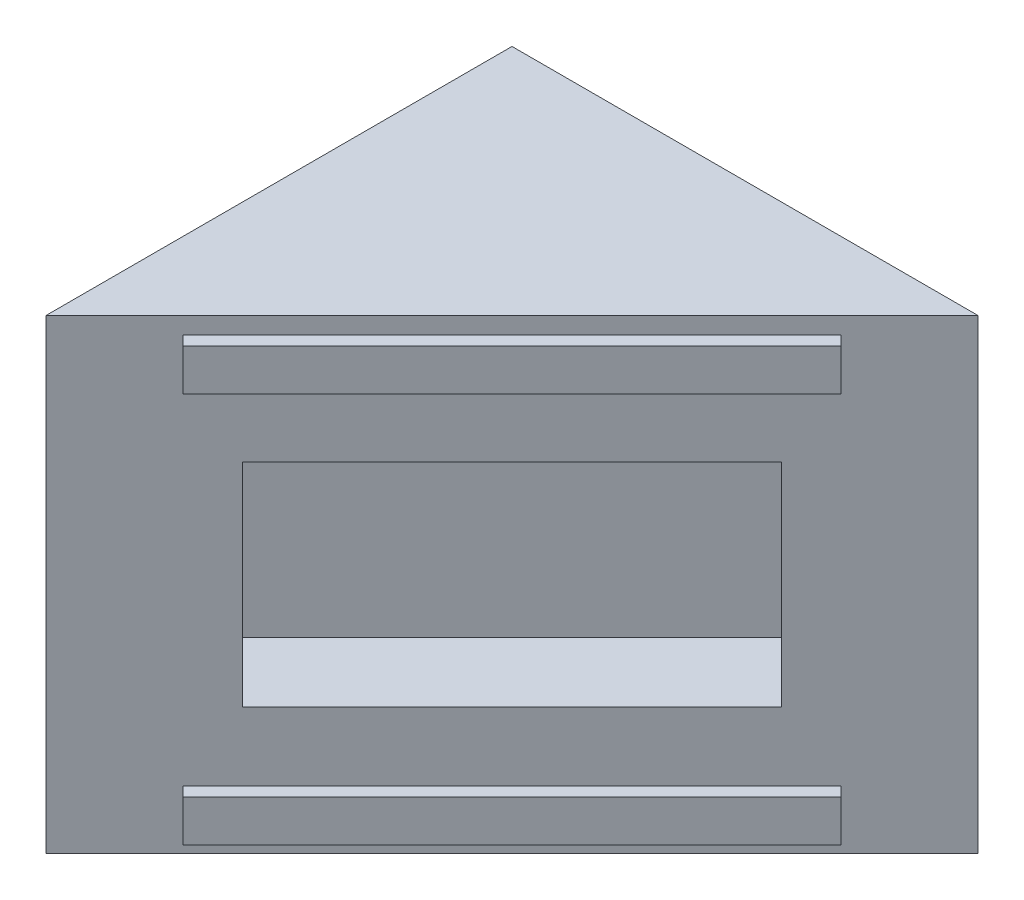
from build123d import *

# Parameters (mm, degrees)
SKETCH1_W           = 69.85
SKETCH1_H           = 69.85
BOSS_EXTRUDE1_DEPTH = 69.85
CUT_EXTRUDE2_DEPTH  = 100
SKETCH3_W           = 69.723
SKETCH3_H           = 6.223
BOSS_EXTRUDE2_DEPTH = 2.032
SKETCH4_W           = 57.15
SKETCH4_H           = 31.75
CUT_EXTRUDE3_DEPTH  = 12.7


with BuildPart() as part:
    # Sketch1 → Boss-Extrude1 (new body)
    with BuildSketch(Plane(origin=(0, 0, 0), x_dir=(1, 0, 0), z_dir=(0, 1, 0))):
        with Locations((34.925, 34.925)):
            Rectangle(SKETCH1_W, SKETCH1_H)
    extrude(amount=BOSS_EXTRUDE1_DEPTH)

    # Sketch2 → Cut-Extrude2 (cut)
    with BuildSketch(Plane(origin=(0, 0, 0), x_dir=(0.707106781, 0, -0.707106781), z_dir=(0.707106781, 0, 0.707106781))):
        Polygon((98.782817332, 69.85), (98.782817332, 0), (49.391408666, 0), (0, 0), (0, 69.85), (49.391408666, 69.85), align=None)
    extrude(amount=CUT_EXTRUDE2_DEPTH, mode=Mode.SUBTRACT)

    # Sketch3 → Boss-Extrude2 (add)
    with BuildSketch(Plane(origin=(0, 0, 0), x_dir=(0.707106781, 0, -0.707106781), z_dir=(0.707106781, 0, 0.707106781))):
        with Locations((49.391408666, 5.6515)):
            Rectangle(SKETCH3_W, SKETCH3_H)
        with Locations((49.391408666, 64.1985)):
            Rectangle(SKETCH3_W, SKETCH3_H)
    extrude(amount=BOSS_EXTRUDE2_DEPTH)

    # Sketch4 → Cut-Extrude3 (cut)
    with BuildSketch(Plane(origin=(0, 0, 0), x_dir=(0.707106781, 0, -0.707106781), z_dir=(0.707106781, 0, 0.707106781))):
        with Locations((49.391408666, 34.925)):
            Rectangle(SKETCH4_W, SKETCH4_H)
    extrude(amount=-CUT_EXTRUDE3_DEPTH, mode=Mode.SUBTRACT)


solid = part.part
